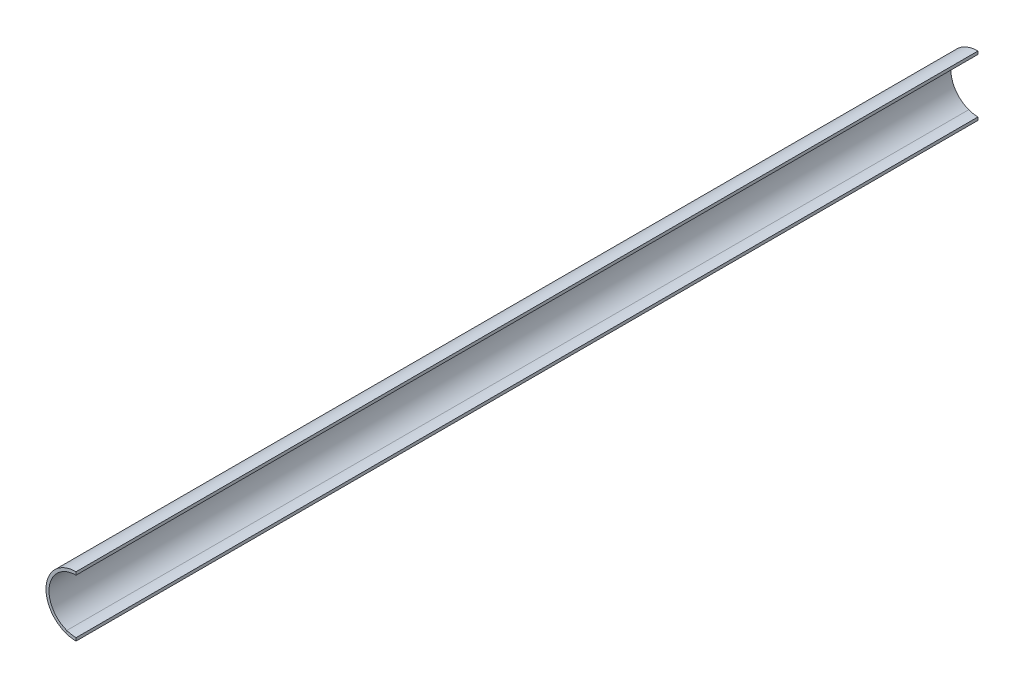
from build123d import *

# Parameters (mm, degrees)
AUFSATZ_LINEAR_AUSTRAGEN1_DEPTH = 300


with BuildPart() as part:
    # Skizze1 → Aufsatz-Linear austragen1 (new body)
    with BuildSketch(Plane.XY):
        with BuildLine():
            Line((0, 10), (0, 9))
            ThreePointArc((0, 9), (-9, 0), (0, -9))
            Line((0, -9), (0, -10))
            ThreePointArc((0, -10), (-10, 0), (0, 10))
        make_face()
    extrude(amount=AUFSATZ_LINEAR_AUSTRAGEN1_DEPTH)


solid = part.part
